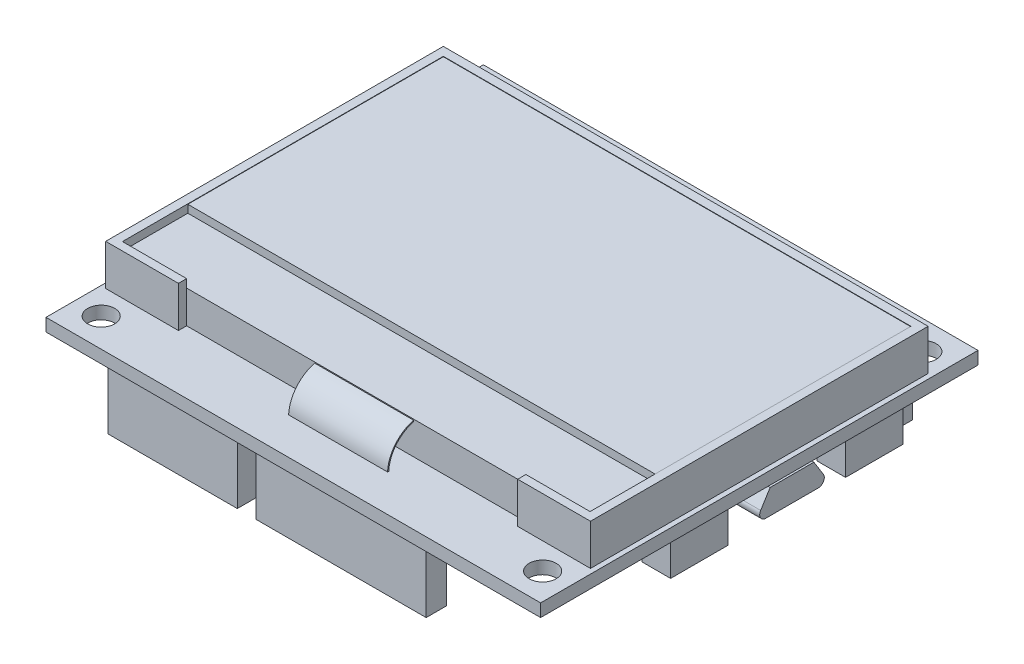
from build123d import *

# Parameters (mm, degrees)
SKETCH1_W                = 60.5
SKETCH1_H                = 53.5
SKETCH1_R                = 1.65
BOSS_EXTRUDE1_DEPTH      = 1.56
SKETCH2_W                = 59.3
SKETCH2_H                = 41.3
BOSS_EXTRUDE2_DEPTH      = 5
SKETCH4_W                = 41.5
SKETCH4_H                = 5
CUT_EXTRUDE1_DEPTH       = 1
BOSS_EXTRUDE3_DEPTH      = 6.05
BOSS_EXTRUDE3_DEPTH_BACK = 6.05
SKETCH5_W                = 15.8
SKETCH5_H                = 2.5
SKETCH5_W_2              = 20.8
SKETCH5_W_3              = 25.9
BOSS_EXTRUDE4_DEPTH      = 8.4
SKETCH6_W                = 3.5
SKETCH6_H                = 7
BOSS_EXTRUDE5_DEPTH      = 4
SKETCH7_W                = 57.2
SKETCH7_H                = 8
CUT_EXTRUDE2_DEPTH       = 1
SKETCH8_W                = 57.2
SKETCH8_H                = 31.25
CUT_EXTRUDE3_DEPTH       = 0.05
SKETCH9_W                = 5.6
SKETCH9_H                = 8
BOSS_EXTRUDE6_DEPTH      = 3
CUT_EXTRUDE4_DEPTH       = 5.6


with BuildPart() as part:
    # Sketch1 → Boss-Extrude1 (new body)
    with BuildSketch(Plane(origin=(0, 0, 0), x_dir=(1, 0, 0), z_dir=(0, 1, 0))):
        with Locations((-0.970473773, 6.36428867)):
            Rectangle(SKETCH1_W, SKETCH1_H)
        with Locations((-27.970473773, -16.88571133)):
            Circle(SKETCH1_R, mode=Mode.SUBTRACT)
        with Locations((-27.970473773, 29.61428867)):
            Circle(SKETCH1_R, mode=Mode.SUBTRACT)
        with Locations((26.029526227, 29.61428867)):
            Circle(SKETCH1_R, mode=Mode.SUBTRACT)
        with Locations((26.029526227, -16.88571133)):
            Circle(SKETCH1_R, mode=Mode.SUBTRACT)
    extrude(amount=BOSS_EXTRUDE1_DEPTH)

    # Sketch2 → Boss-Extrude2 (add)
    with BuildSketch(Plane(origin=(0, 1.56, 0), x_dir=(1, 0, 0), z_dir=(0, 1, 0))):
        with Locations((-0.970473773, 6.96428867)):
            Rectangle(SKETCH2_W, SKETCH2_H)
    extrude(amount=BOSS_EXTRUDE2_DEPTH)

    # Sketch4 → Cut-Extrude1 (cut)
    with BuildSketch(Plane.XY.offset(13.68571133)):
        with Locations((-0.970473773, 4.06)):
            Rectangle(SKETCH4_W, SKETCH4_H)
    extrude(amount=-CUT_EXTRUDE1_DEPTH, mode=Mode.SUBTRACT)

    # Sketch3 → Boss-Extrude3 (add, two sides)
    with BuildSketch(Plane(origin=(0, 0, 0), x_dir=(0, 0, -1), z_dir=(1, 0, 0))) as boss_extrude3_sk:
        with BuildLine():
            Line((-11.68571133, 5.41), (-11.68571133, 5.56))
            ThreePointArc((-11.68571133, 5.56), (-14.583986679, 4.399736831), (-15.880946723, 1.56))
            Line((-15.880946723, 1.56), (-15.730770044, 1.56))
            ThreePointArc((-15.730770044, 1.56), (-14.4778879, 4.293641082), (-11.68571133, 5.41))
        make_face()
    extrude(amount=BOSS_EXTRUDE3_DEPTH)
    extrude(boss_extrude3_sk.sketch, amount=-BOSS_EXTRUDE3_DEPTH_BACK)

    # Sketch5 → Boss-Extrude4 (add)
    with BuildSketch(Plane(origin=(0, 0, 0), x_dir=(-1, 0, 0), z_dir=(0, -1, 0))):
        with Locations((17.120473773, -17.73571133)):
            Rectangle(SKETCH5_W, SKETCH5_H)
        with Locations((-3.479526227, -17.73571133)):
            Rectangle(SKETCH5_W_2, SKETCH5_H)
        with Locations((14.620473773, 30.46428867)):
            Rectangle(SKETCH5_W_2, SKETCH5_H)
        with Locations((-9.729526227, 30.46428867)):
            Rectangle(SKETCH5_W_3, SKETCH5_H)
    extrude(amount=BOSS_EXTRUDE4_DEPTH)

    # Sketch6 → Boss-Extrude5 (add)
    with BuildSketch(Plane.XZ):
        with Locations((-29.270473773, 0.78571133)):
            Rectangle(SKETCH6_W, SKETCH6_H)
        with Locations((-29.270473773, -20.61428867)):
            Rectangle(SKETCH6_W, SKETCH6_H)
        with Locations((27.329526227, 0.78571133)):
            Rectangle(SKETCH6_W, SKETCH6_H)
        with Locations((27.329526227, -20.61428867)):
            Rectangle(SKETCH6_W, SKETCH6_H)
    extrude(amount=BOSS_EXTRUDE5_DEPTH)

    # Sketch7 → Cut-Extrude2 (cut)
    with BuildSketch(Plane(origin=(0, 6.56, 0), x_dir=(1, 0, 0), z_dir=(0, 1, 0))):
        with Locations((-0.970473773, -8.68571133)):
            Rectangle(SKETCH7_W, SKETCH7_H)
    extrude(amount=-CUT_EXTRUDE2_DEPTH, mode=Mode.SUBTRACT)

    # Sketch8 → Cut-Extrude3 (cut)
    with BuildSketch(Plane(origin=(0, 6.56, 0), x_dir=(1, 0, 0), z_dir=(0, 1, 0))):
        with Locations((-0.970473773, 10.93928867)):
            Rectangle(SKETCH8_W, SKETCH8_H)
    extrude(amount=-CUT_EXTRUDE3_DEPTH, mode=Mode.SUBTRACT)

    # Sketch9 → Boss-Extrude6 (add)
    with BuildSketch(Plane(origin=(0, 0, 0), x_dir=(-1, 0, 0), z_dir=(0, -1, 0))):
        with Locations((-26.729526227, 10.11428867)):
            Rectangle(SKETCH9_W, SKETCH9_H)
    extrude(amount=BOSS_EXTRUDE6_DEPTH)

    # Sketch10 → Cut-Extrude4 (cut)
    with BuildSketch(Plane(origin=(29.529526227, 0, 0), x_dir=(0, 0, -1), z_dir=(1, 0, 0))):
        with BuildLine():
            Line((7.436374303, 0), (6.278331815, -1.852433806))
            ThreePointArc((6.278331815, -1.852433806), (6.258287662, -2.613541851), (6.91428867, -3))
            Line((6.91428867, -3), (6.11428867, -3))
            Line((6.11428867, -3), (6.11428867, 0))
            Line((6.11428867, 0), (7.436374303, 0))
        make_face()
        with BuildLine():
            Line((12.792203037, 0), (13.950245525, -1.852433806))
            ThreePointArc((13.950245525, -1.852433806), (13.970289678, -2.613541851), (13.31428867, -3))
            Line((13.31428867, -3), (14.11428867, -3))
            Line((14.11428867, -3), (14.11428867, 0))
            Line((14.11428867, 0), (12.792203037, 0))
        make_face()
    extrude(amount=-CUT_EXTRUDE4_DEPTH, mode=Mode.SUBTRACT)


solid = part.part
